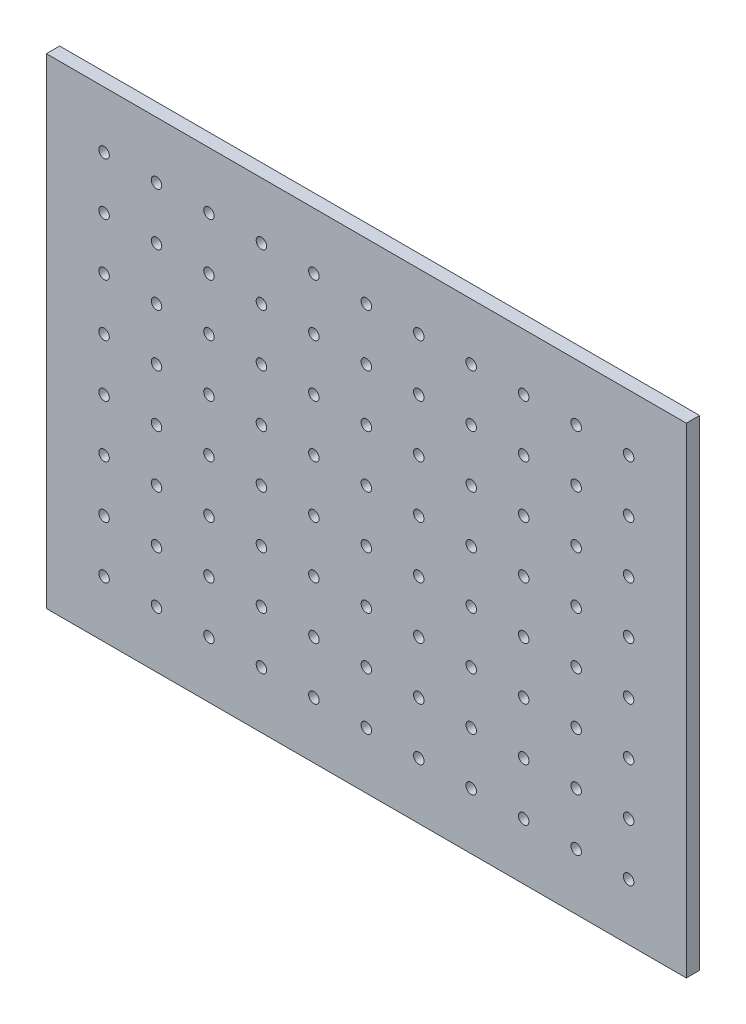
from build123d import *

# Parameters (mm, degrees)
ESBO_O2_W                = 610
ESBO_O2_H                = 458
ESBO_O2_R                = 5
RESSALTO_EXTRUS_O2_DEPTH = 12.7


with BuildPart() as part:
    # Esboço2 → Ressalto-extrusão2 (new body)
    with BuildSketch(Plane.XY):
        with Locations((182.869428212, 139.767594323)):
            Rectangle(ESBO_O2_W, ESBO_O2_H)
        with Locations((-67.130571788, -35.232405677)):
            Circle(ESBO_O2_R, mode=Mode.SUBTRACT)
        with Locations((-17.130571788, -35.232405677)):
            Circle(ESBO_O2_R, mode=Mode.SUBTRACT)
        with Locations((32.869428212, -35.232405677)):
            Circle(ESBO_O2_R, mode=Mode.SUBTRACT)
        with Locations((82.869428212, -35.232405677)):
            Circle(ESBO_O2_R, mode=Mode.SUBTRACT)
        with Locations((132.869428212, -35.232405677)):
            Circle(ESBO_O2_R, mode=Mode.SUBTRACT)
        with Locations((182.869428212, -35.232405677)):
            Circle(ESBO_O2_R, mode=Mode.SUBTRACT)
        with Locations((232.869428212, -35.232405677)):
            Circle(ESBO_O2_R, mode=Mode.SUBTRACT)
        with Locations((282.869428212, -35.232405677)):
            Circle(ESBO_O2_R, mode=Mode.SUBTRACT)
        with Locations((332.869428212, -35.232405677)):
            Circle(ESBO_O2_R, mode=Mode.SUBTRACT)
        with Locations((382.869428212, -35.232405677)):
            Circle(ESBO_O2_R, mode=Mode.SUBTRACT)
        with Locations((432.869428212, -35.232405677)):
            Circle(ESBO_O2_R, mode=Mode.SUBTRACT)
        with Locations((-17.130571788, 14.767594323)):
            Circle(ESBO_O2_R, mode=Mode.SUBTRACT)
        with Locations((32.869428212, 14.767594323)):
            Circle(ESBO_O2_R, mode=Mode.SUBTRACT)
        with Locations((82.869428212, 14.767594323)):
            Circle(ESBO_O2_R, mode=Mode.SUBTRACT)
        with Locations((132.869428212, 14.767594323)):
            Circle(ESBO_O2_R, mode=Mode.SUBTRACT)
        with Locations((182.869428212, 14.767594323)):
            Circle(ESBO_O2_R, mode=Mode.SUBTRACT)
        with Locations((232.869428212, 14.767594323)):
            Circle(ESBO_O2_R, mode=Mode.SUBTRACT)
        with Locations((282.869428212, 14.767594323)):
            Circle(ESBO_O2_R, mode=Mode.SUBTRACT)
        with Locations((332.869428212, 14.767594323)):
            Circle(ESBO_O2_R, mode=Mode.SUBTRACT)
        with Locations((382.869428212, 14.767594323)):
            Circle(ESBO_O2_R, mode=Mode.SUBTRACT)
        with Locations((432.869428212, 14.767594323)):
            Circle(ESBO_O2_R, mode=Mode.SUBTRACT)
        with Locations((-17.130571788, 64.767594323)):
            Circle(ESBO_O2_R, mode=Mode.SUBTRACT)
        with Locations((32.869428212, 64.767594323)):
            Circle(ESBO_O2_R, mode=Mode.SUBTRACT)
        with Locations((82.869428212, 64.767594323)):
            Circle(ESBO_O2_R, mode=Mode.SUBTRACT)
        with Locations((132.869428212, 64.767594323)):
            Circle(ESBO_O2_R, mode=Mode.SUBTRACT)
        with Locations((182.869428212, 64.767594323)):
            Circle(ESBO_O2_R, mode=Mode.SUBTRACT)
        with Locations((232.869428212, 64.767594323)):
            Circle(ESBO_O2_R, mode=Mode.SUBTRACT)
        with Locations((282.869428212, 64.767594323)):
            Circle(ESBO_O2_R, mode=Mode.SUBTRACT)
        with Locations((332.869428212, 64.767594323)):
            Circle(ESBO_O2_R, mode=Mode.SUBTRACT)
        with Locations((382.869428212, 64.767594323)):
            Circle(ESBO_O2_R, mode=Mode.SUBTRACT)
        with Locations((432.869428212, 64.767594323)):
            Circle(ESBO_O2_R, mode=Mode.SUBTRACT)
        with Locations((-17.130571788, 114.767594323)):
            Circle(ESBO_O2_R, mode=Mode.SUBTRACT)
        with Locations((32.869428212, 114.767594323)):
            Circle(ESBO_O2_R, mode=Mode.SUBTRACT)
        with Locations((82.869428212, 114.767594323)):
            Circle(ESBO_O2_R, mode=Mode.SUBTRACT)
        with Locations((132.869428212, 114.767594323)):
            Circle(ESBO_O2_R, mode=Mode.SUBTRACT)
        with Locations((182.869428212, 114.767594323)):
            Circle(ESBO_O2_R, mode=Mode.SUBTRACT)
        with Locations((232.869428212, 114.767594323)):
            Circle(ESBO_O2_R, mode=Mode.SUBTRACT)
        with Locations((282.869428212, 114.767594323)):
            Circle(ESBO_O2_R, mode=Mode.SUBTRACT)
        with Locations((332.869428212, 114.767594323)):
            Circle(ESBO_O2_R, mode=Mode.SUBTRACT)
        with Locations((382.869428212, 114.767594323)):
            Circle(ESBO_O2_R, mode=Mode.SUBTRACT)
        with Locations((432.869428212, 114.767594323)):
            Circle(ESBO_O2_R, mode=Mode.SUBTRACT)
        with Locations((-17.130571788, 164.767594323)):
            Circle(ESBO_O2_R, mode=Mode.SUBTRACT)
        with Locations((32.869428212, 164.767594323)):
            Circle(ESBO_O2_R, mode=Mode.SUBTRACT)
        with Locations((82.869428212, 164.767594323)):
            Circle(ESBO_O2_R, mode=Mode.SUBTRACT)
        with Locations((132.869428212, 164.767594323)):
            Circle(ESBO_O2_R, mode=Mode.SUBTRACT)
        with Locations((182.869428212, 164.767594323)):
            Circle(ESBO_O2_R, mode=Mode.SUBTRACT)
        with Locations((232.869428212, 164.767594323)):
            Circle(ESBO_O2_R, mode=Mode.SUBTRACT)
        with Locations((282.869428212, 164.767594323)):
            Circle(ESBO_O2_R, mode=Mode.SUBTRACT)
        with Locations((332.869428212, 164.767594323)):
            Circle(ESBO_O2_R, mode=Mode.SUBTRACT)
        with Locations((382.869428212, 164.767594323)):
            Circle(ESBO_O2_R, mode=Mode.SUBTRACT)
        with Locations((432.869428212, 164.767594323)):
            Circle(ESBO_O2_R, mode=Mode.SUBTRACT)
        with Locations((-17.130571788, 214.767594323)):
            Circle(ESBO_O2_R, mode=Mode.SUBTRACT)
        with Locations((32.869428212, 214.767594323)):
            Circle(ESBO_O2_R, mode=Mode.SUBTRACT)
        with Locations((82.869428212, 214.767594323)):
            Circle(ESBO_O2_R, mode=Mode.SUBTRACT)
        with Locations((132.869428212, 214.767594323)):
            Circle(ESBO_O2_R, mode=Mode.SUBTRACT)
        with Locations((182.869428212, 214.767594323)):
            Circle(ESBO_O2_R, mode=Mode.SUBTRACT)
        with Locations((232.869428212, 214.767594323)):
            Circle(ESBO_O2_R, mode=Mode.SUBTRACT)
        with Locations((282.869428212, 214.767594323)):
            Circle(ESBO_O2_R, mode=Mode.SUBTRACT)
        with Locations((332.869428212, 214.767594323)):
            Circle(ESBO_O2_R, mode=Mode.SUBTRACT)
        with Locations((382.869428212, 214.767594323)):
            Circle(ESBO_O2_R, mode=Mode.SUBTRACT)
        with Locations((432.869428212, 214.767594323)):
            Circle(ESBO_O2_R, mode=Mode.SUBTRACT)
        with Locations((-17.130571788, 264.767594323)):
            Circle(ESBO_O2_R, mode=Mode.SUBTRACT)
        with Locations((32.869428212, 264.767594323)):
            Circle(ESBO_O2_R, mode=Mode.SUBTRACT)
        with Locations((82.869428212, 264.767594323)):
            Circle(ESBO_O2_R, mode=Mode.SUBTRACT)
        with Locations((132.869428212, 264.767594323)):
            Circle(ESBO_O2_R, mode=Mode.SUBTRACT)
        with Locations((182.869428212, 264.767594323)):
            Circle(ESBO_O2_R, mode=Mode.SUBTRACT)
        with Locations((232.869428212, 264.767594323)):
            Circle(ESBO_O2_R, mode=Mode.SUBTRACT)
        with Locations((282.869428212, 264.767594323)):
            Circle(ESBO_O2_R, mode=Mode.SUBTRACT)
        with Locations((332.869428212, 264.767594323)):
            Circle(ESBO_O2_R, mode=Mode.SUBTRACT)
        with Locations((382.869428212, 264.767594323)):
            Circle(ESBO_O2_R, mode=Mode.SUBTRACT)
        with Locations((432.869428212, 264.767594323)):
            Circle(ESBO_O2_R, mode=Mode.SUBTRACT)
        with Locations((-17.130571788, 314.767594323)):
            Circle(ESBO_O2_R, mode=Mode.SUBTRACT)
        with Locations((32.869428212, 314.767594323)):
            Circle(ESBO_O2_R, mode=Mode.SUBTRACT)
        with Locations((82.869428212, 314.767594323)):
            Circle(ESBO_O2_R, mode=Mode.SUBTRACT)
        with Locations((132.869428212, 314.767594323)):
            Circle(ESBO_O2_R, mode=Mode.SUBTRACT)
        with Locations((182.869428212, 314.767594323)):
            Circle(ESBO_O2_R, mode=Mode.SUBTRACT)
        with Locations((232.869428212, 314.767594323)):
            Circle(ESBO_O2_R, mode=Mode.SUBTRACT)
        with Locations((282.869428212, 314.767594323)):
            Circle(ESBO_O2_R, mode=Mode.SUBTRACT)
        with Locations((332.869428212, 314.767594323)):
            Circle(ESBO_O2_R, mode=Mode.SUBTRACT)
        with Locations((382.869428212, 314.767594323)):
            Circle(ESBO_O2_R, mode=Mode.SUBTRACT)
        with Locations((432.869428212, 314.767594323)):
            Circle(ESBO_O2_R, mode=Mode.SUBTRACT)
        with Locations((-67.130571788, 14.767594323)):
            Circle(ESBO_O2_R, mode=Mode.SUBTRACT)
        with Locations((-67.130571788, 64.767594323)):
            Circle(ESBO_O2_R, mode=Mode.SUBTRACT)
        with Locations((-67.130571788, 114.767594323)):
            Circle(ESBO_O2_R, mode=Mode.SUBTRACT)
        with Locations((-67.130571788, 164.767594323)):
            Circle(ESBO_O2_R, mode=Mode.SUBTRACT)
        with Locations((-67.130571788, 214.767594323)):
            Circle(ESBO_O2_R, mode=Mode.SUBTRACT)
        with Locations((-67.130571788, 264.767594323)):
            Circle(ESBO_O2_R, mode=Mode.SUBTRACT)
        with Locations((-67.130571788, 314.767594323)):
            Circle(ESBO_O2_R, mode=Mode.SUBTRACT)
    extrude(amount=RESSALTO_EXTRUS_O2_DEPTH)


solid = part.part
